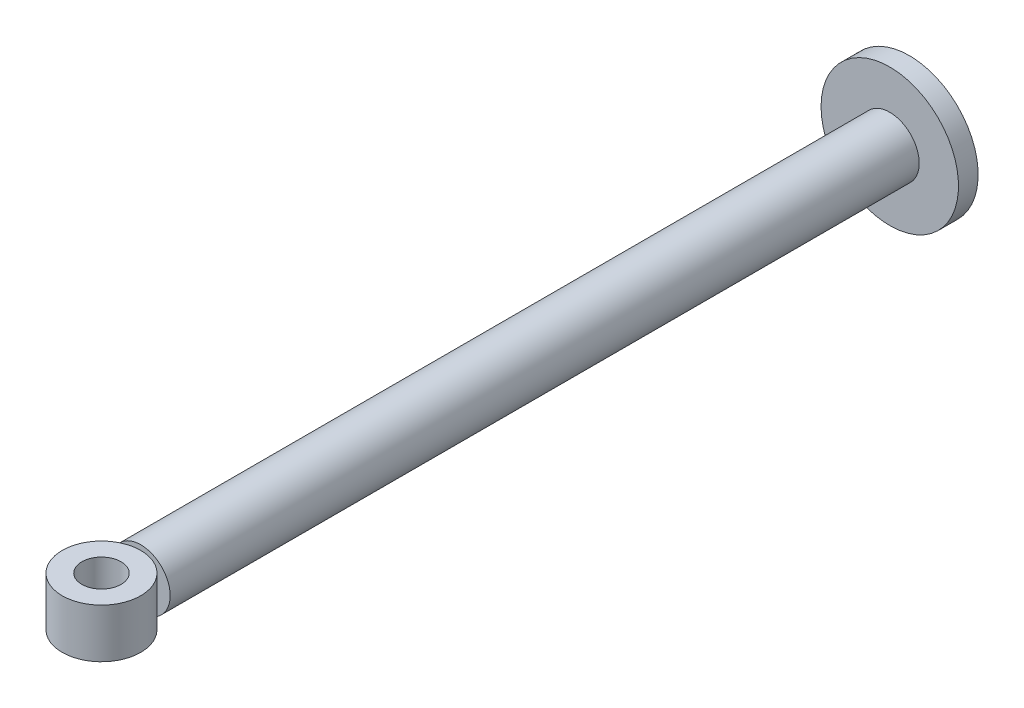
from build123d import *

# Parameters (mm, degrees)
SKETCH1_R                = 3
BOSS_EXTRUDE1_DEPTH      = 78.3
BOSS_EXTRUDE2_DEPTH      = 2.5
BOSS_EXTRUDE2_DEPTH_BACK = 2.5
SKETCH2_R                = 4
SKETCH2_R_2              = 2
SKETCH3_R                = 7
BOSS_EXTRUDE3_DEPTH      = 2


with BuildPart() as part:
    # Sketch1 → Boss-Extrude1 (new body)
    with BuildSketch(Plane.XY):
        Circle(SKETCH1_R)
    extrude(amount=BOSS_EXTRUDE1_DEPTH)

    # Sketch3 → Boss-Extrude3 (add)
    with BuildSketch(Plane(origin=(0, 0, 0), x_dir=(-1, 0, 0), z_dir=(0, 0, -1))):
        Circle(SKETCH3_R)
    extrude(amount=-BOSS_EXTRUDE3_DEPTH)


with BuildPart() as body_2:
    # Sketch2 → Boss-Extrude2 (new, two sides: drawn at the far end of the back side and taken through both)
    with BuildSketch(Plane(origin=(0, 0, 0), x_dir=(1, 0, 0), z_dir=(0, 1, 0)).offset(-BOSS_EXTRUDE2_DEPTH_BACK)):
        with Locations((0, -82.3)):
            Circle(SKETCH2_R)
        with Locations((0, -82.3)):
            Circle(SKETCH2_R_2, mode=Mode.SUBTRACT)
    extrude(amount=BOSS_EXTRUDE2_DEPTH + BOSS_EXTRUDE2_DEPTH_BACK)


solid = Compound([part.part, body_2.part])
